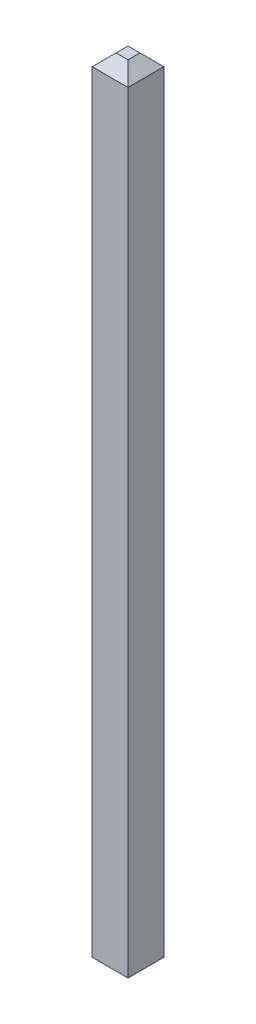
from build123d import *

# Parameters (mm, degrees)
SKETCH1_W                = 5.5
SKETCH1_H                = 2.5
BOSS_EXTRUDE1_DEPTH      = 2.5
BOSS_EXTRUDE2_START      = -10.8
SKETCH2_W                = 0.6
SKETCH2_H                = 0.6
BOSS_EXTRUDE2_DEPTH      = 13.3
CHAMFER1_SIZE            = 0.2
CHAMFER1_OF_MIRROR1_SIZE = 0.2
SKETCH3_W                = 12.315136804
SKETCH3_H                = 10.630786544
SKETCH3_W_2              = 0.6
SKETCH3_H_2              = 0.6
CUT_EXTRUDE2_DEPTH       = 10
CUT_EXTRUDE2_DEPTH_BACK  = 30


with BuildPart() as part:
    # Sketch1 → Boss-Extrude1 (new body)
    with BuildSketch(Plane(origin=(0, 0, 0), x_dir=(1, 0, 0), z_dir=(0, 1, 0))):
        Rectangle(SKETCH1_W, SKETCH1_H)
    extrude(amount=BOSS_EXTRUDE1_DEPTH)

    # Sketch2 → Boss-Extrude2 (add)
    with BuildSketch(Plane(origin=(0, 2.5, 0), x_dir=(1, 0, 0), z_dir=(0, 1, 0)).offset(BOSS_EXTRUDE2_START)):
        with Locations((-1.25, 0)):
            Rectangle(SKETCH2_W, SKETCH2_H)
    boss_extrude2 = extrude(amount=BOSS_EXTRUDE2_DEPTH)

    # Chamfer1
    chamfer1_edges = [part.edges().sort_by_distance(p)[0] for p in [
        (-1.55, -8.3, 0),
        (-1.25, -8.3, -0.3),
        (-0.95, -8.3, 0),
        (-1.25, -8.3, 0.3),
        (-1.55, 5, 0),
        (-1.25, 5, 0.3),
        (-0.95, 5, 0),
        (-1.25, 5, -0.3),
    ]]
    chamfer(chamfer1_edges, length=CHAMFER1_SIZE)

    # Mirror1: Boss-Extrude2 across plane
    add(boss_extrude2.mirror(Plane(origin=(0, 0, 0), x_dir=(0, 0, 1), z_dir=(1, 0, 0))))

    # Chamfer1 of Mirror1
    chamfer1_of_mirror1_edges = [part.edges().sort_by_distance(p)[0] for p in [
        (1.55, -8.3, 0),
        (1.25, -8.3, -0.3),
        (0.95, -8.3, 0),
        (1.25, -8.3, 0.3),
        (1.55, 5, 0),
        (1.25, 5, 0.3),
        (0.95, 5, 0),
        (1.25, 5, -0.3),
    ]]
    chamfer(chamfer1_of_mirror1_edges, length=CHAMFER1_OF_MIRROR1_SIZE)

    # Sketch3 → Cut-Extrude2 (cut, two sides)
    with BuildSketch(Plane(origin=(0, 2.5, 0), x_dir=(1, 0, 0), z_dir=(0, 1, 0))) as cut_extrude2_sk:
        with Locations((0.038795384, 0.437700071)):
            Rectangle(SKETCH3_W, SKETCH3_H)
        with Locations((-1.25, 0)):
            Rectangle(SKETCH3_W_2, SKETCH3_H_2, mode=Mode.SUBTRACT)
    extrude(amount=CUT_EXTRUDE2_DEPTH, mode=Mode.SUBTRACT)
    extrude(cut_extrude2_sk.sketch, amount=-CUT_EXTRUDE2_DEPTH_BACK, mode=Mode.SUBTRACT)


solid = part.part
